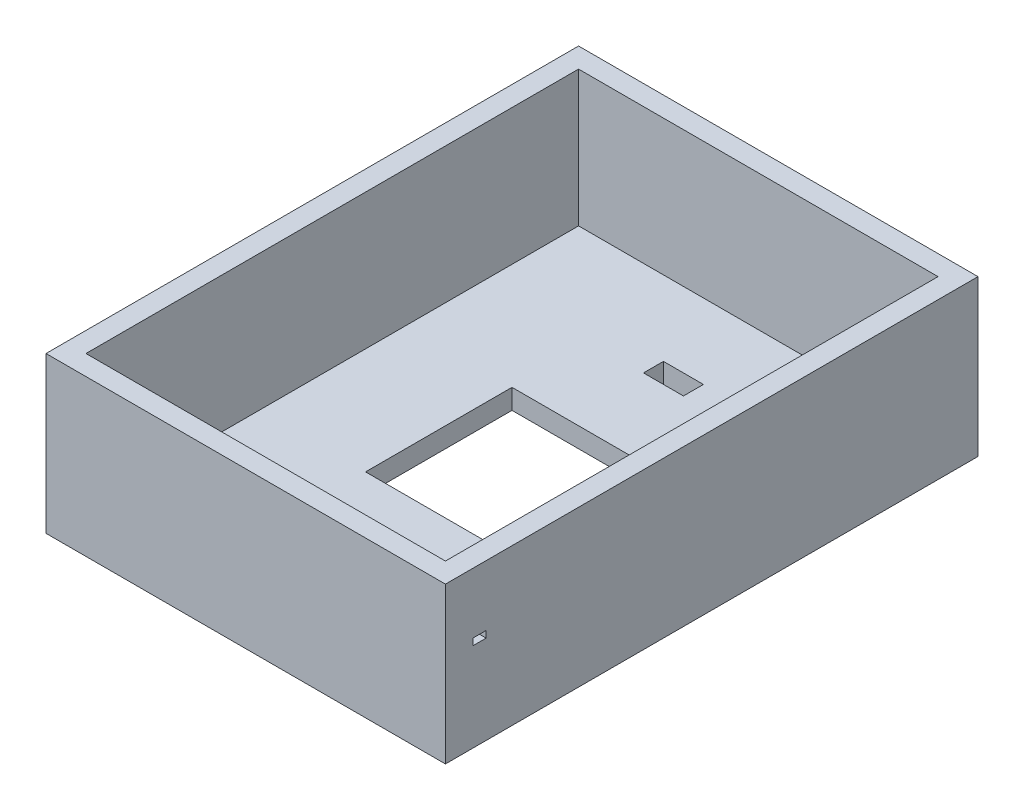
from build123d import *

# Parameters (mm, degrees)
SKETCH1_W           = 300
SKETCH1_H           = 400
BOSS_EXTRUDE2_DEPTH = 117
SKETCH3_W           = 110
SKETCH3_H           = 110
CUT_EXTRUDE2_DEPTH  = 117
SKETCH5_W           = 270
SKETCH5_H           = 370
CUT_EXTRUDE3_DEPTH  = 102
SKETCH7_W           = 30
SKETCH7_H           = 15
CUT_EXTRUDE5_DEPTH  = 102
SKETCH8_W           = 10
SKETCH8_H           = 5
CUT_EXTRUDE7_DEPTH  = 90
SKETCH9_R           = 2.5
CUT_EXTRUDE8_DEPTH  = 90
SKETCH10_R          = 4
CUT_EXTRUDE9_DEPTH  = 90


with BuildPart() as part:
    # Sketch1 → Boss-Extrude2 (new body)
    with BuildSketch(Plane(origin=(0, 0, 0), x_dir=(1, 0, 0), z_dir=(0, 1, 0))):
        Rectangle(SKETCH1_W, SKETCH1_H)
    extrude(amount=BOSS_EXTRUDE2_DEPTH)

    # Sketch3 → Cut-Extrude2 (cut)
    with BuildSketch(Plane(origin=(0, 117, 0), x_dir=(1, 0, 0), z_dir=(0, 1, 0))):
        Rectangle(SKETCH3_W, SKETCH3_H)
    extrude(amount=-CUT_EXTRUDE2_DEPTH, mode=Mode.SUBTRACT)

    # Sketch5 → Cut-Extrude3 (cut)
    with BuildSketch(Plane(origin=(0, 117, 0), x_dir=(1, 0, 0), z_dir=(0, 1, 0))):
        Rectangle(SKETCH5_W, SKETCH5_H)
    extrude(amount=-CUT_EXTRUDE3_DEPTH, mode=Mode.SUBTRACT)

    # Sketch7 → Cut-Extrude5 (cut)
    with BuildSketch(Plane(origin=(0, 15, 0), x_dir=(1, 0, 0), z_dir=(0, 1, 0))):
        with Locations((0, 121.254101577)):
            Rectangle(SKETCH7_W, SKETCH7_H)
    extrude(amount=-CUT_EXTRUDE5_DEPTH, mode=Mode.SUBTRACT)

    # Sketch8 → Cut-Extrude7 (cut)
    with BuildSketch(Plane(origin=(150, 0, 0), x_dir=(0, 0, -1), z_dir=(1, 0, 0))):
        with Locations((-174.402323873, 69.081419449)):
            Rectangle(SKETCH8_W, SKETCH8_H)
    extrude(amount=-CUT_EXTRUDE7_DEPTH, mode=Mode.SUBTRACT)

    # Sketch9 → Cut-Extrude8 (cut)
    with BuildSketch(Plane.ZY.offset(150)):
        with Locations((181.740675273, 45.527316057)):
            Circle(SKETCH9_R)
        with Locations((165.218795702, 45.527316057)):
            Circle(SKETCH9_R)
        with Locations((144.15339925, 45.527316057)):
            Circle(SKETCH9_R)
        with Locations((123.088002798, 45.527316057)):
            Circle(SKETCH9_R)
    extrude(amount=-CUT_EXTRUDE8_DEPTH, mode=Mode.SUBTRACT)

    # Sketch10 → Cut-Extrude9 (cut)
    with BuildSketch(Plane(origin=(0, 15, 0), x_dir=(1, 0, 0), z_dir=(0, 1, 0))):
        with Locations((114.515150382, 165.914920232)):
            Circle(SKETCH10_R)
    extrude(amount=-CUT_EXTRUDE9_DEPTH, mode=Mode.SUBTRACT)


solid = part.part
